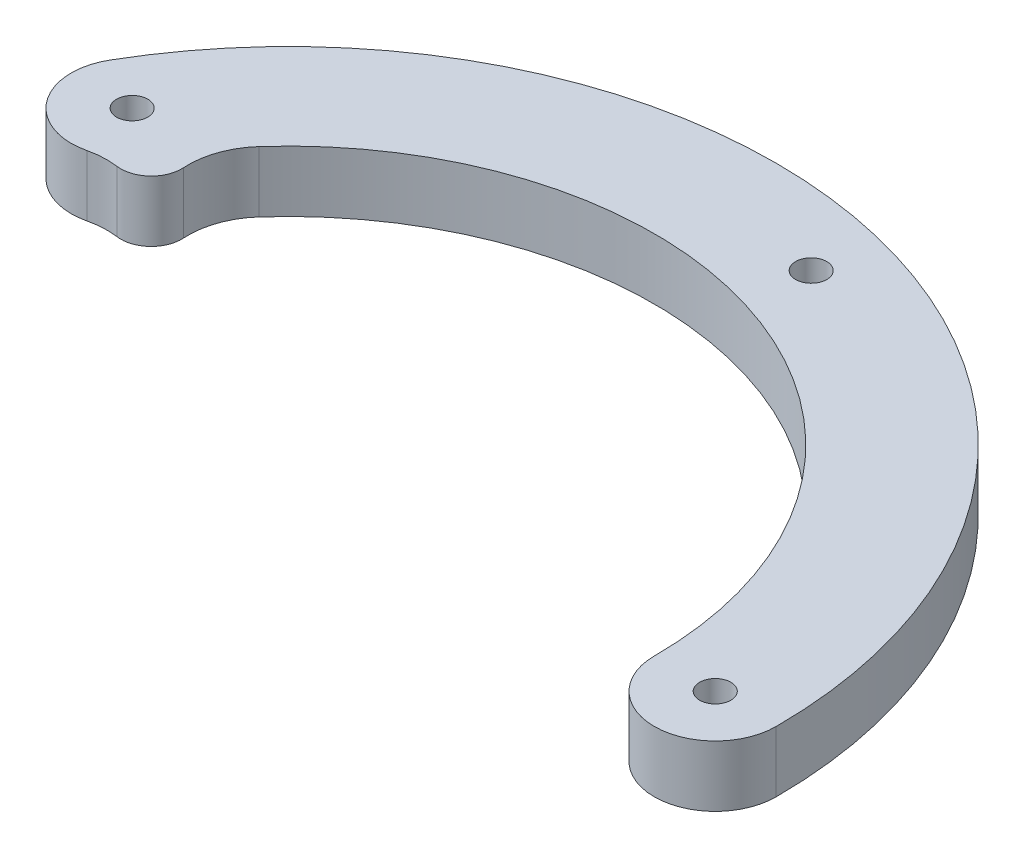
from build123d import *

# Parameters (mm, degrees)
SKETCH1_R           = 1.625
BOSS_EXTRUDE1_DEPTH = 6.35


with BuildPart() as part:
    # Sketch1 → Boss-Extrude1 (new body)
    with BuildSketch(Plane(origin=(0, 0, 0), x_dir=(1, 0, 0), z_dir=(0, 1, 0))):
        with BuildLine():
            ThreePointArc((50.8, 0), (13.148007491, 49.069031975), (-43.994090512, 25.4))
            ThreePointArc((-43.994090512, 25.4), (-43.585026823, 18.428634878), (-37.019722443, 16.048709846))
            ThreePointArc((-37.019722443, 16.048709846), (-35.546093598, 16.258298381), (-34.059144925, 16.191268754))
            ThreePointArc((-34.059144925, 16.191268754), (-31.463683221, 17.007149664), (-30.452841612, 19.533071743))
            ThreePointArc((-30.452841612, 19.533071743), (-30.028839685, 22.644562363), (-28.439901214, 25.353146135))
            ThreePointArc((-28.439901214, 25.353146135), (13.565577093, 35.603161631), (38.1, 0))
            ThreePointArc((38.1, 0), (44.45, -6.35), (50.8, 0))
        make_face()
        with Locations((-38.494829198, 22.225)):
            Circle(SKETCH1_R, mode=Mode.SUBTRACT)
        with Locations((44.45, 0)):
            Circle(SKETCH1_R, mode=Mode.SUBTRACT)
        with Locations((11.504506555, 42.935402979)):
            Circle(SKETCH1_R, mode=Mode.SUBTRACT)
    extrude(amount=BOSS_EXTRUDE1_DEPTH)


solid = part.part
